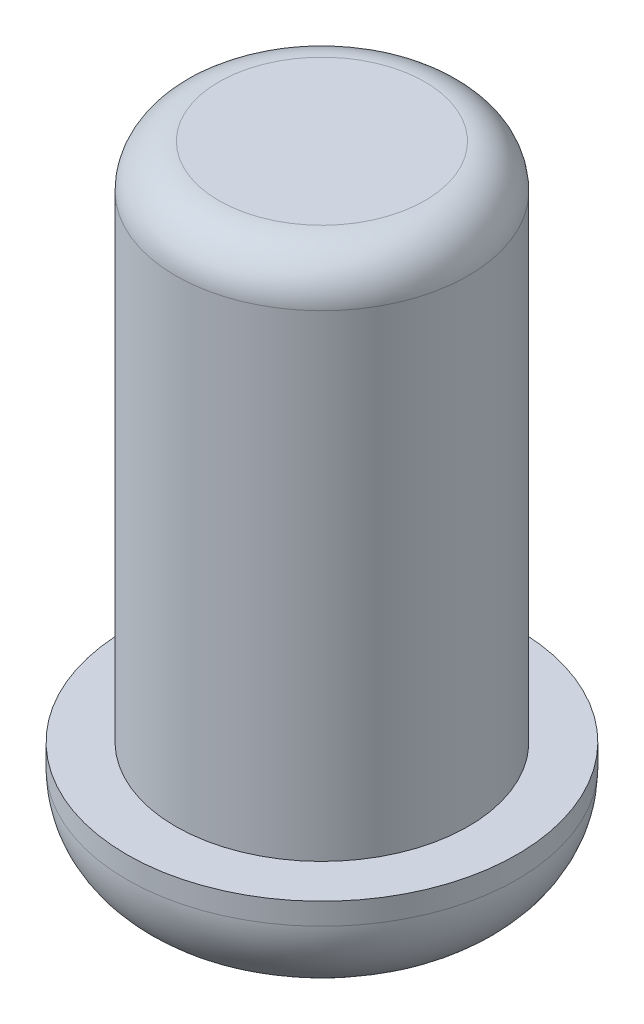
from build123d import *

# Parameters (mm, degrees)
SKETCH1_R           = 0.675
BOSS_EXTRUDE1_DEPTH = 2.4
SKETCH1_3_R         = 0.9
BOSS_EXTRUDE2_DEPTH = 0.5
FILLET1_R           = 0.4
FILLET2_R           = 0.2


with BuildPart() as part:
    # Sketch1 → Boss-Extrude1 (new body)
    with BuildSketch(Plane(origin=(0, 0, 0), x_dir=(1, 0, 0), z_dir=(0, 1, 0))):
        Circle(SKETCH1_R)
    extrude(amount=BOSS_EXTRUDE1_DEPTH)

    # Sketch1_3 → Boss-Extrude2 (add)
    with BuildSketch(Plane(origin=(0, 0, 0), x_dir=(1, 0, 0), z_dir=(0, 1, 0))):
        Circle(SKETCH1_3_R)
    extrude(amount=-BOSS_EXTRUDE2_DEPTH)

    # Fillet1
    fillet1_edges = [part.edges().sort_by_distance(p)[0] for p in [
        (-0.9, -0.5, 0),
    ]]
    fillet(fillet1_edges, radius=FILLET1_R)

    # Fillet2
    fillet2_edges = [part.edges().sort_by_distance(p)[0] for p in [
        (-0.675, 2.4, 0),
    ]]
    fillet(fillet2_edges, radius=FILLET2_R)


solid = part.part
